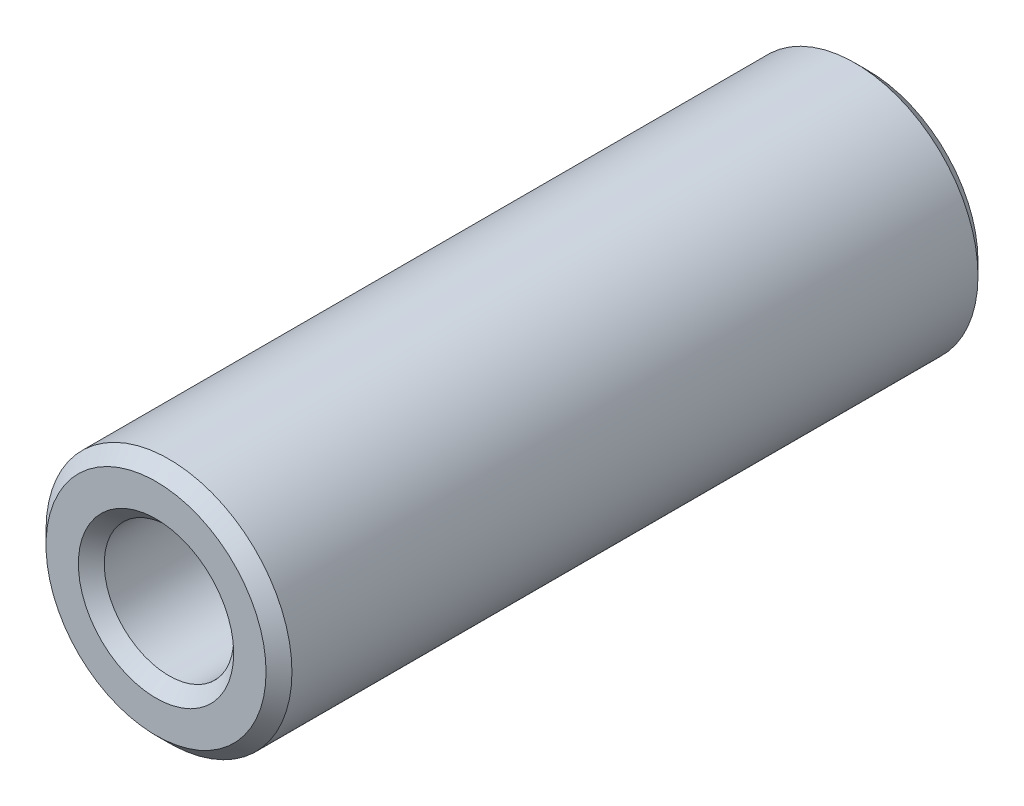
from build123d import *

# Parameters (mm, degrees)
SKETCH_1_R      = 9.5
SKETCH_1_R_2    = 5
EXTRUDE_1_DEPTH = 55
CHAMFER_1_SIZE  = 1


with BuildPart() as part:
    # Эскиз1 → Бобышка-Вытянуть1 (new body)
    with BuildSketch(Plane.XY):
        Circle(SKETCH_1_R)
        Circle(SKETCH_1_R_2, mode=Mode.SUBTRACT)
    extrude(amount=EXTRUDE_1_DEPTH)

    # Фаска1
    chamfer_1_edges = [part.edges().sort_by_distance(p)[0] for p in [
        (-9.5, 0, 0),
        (-9.5, 0, 55),
        (-5, 0, 0),
        (-5, 0, 55),
    ]]
    chamfer(chamfer_1_edges, length=CHAMFER_1_SIZE)


solid = part.part
